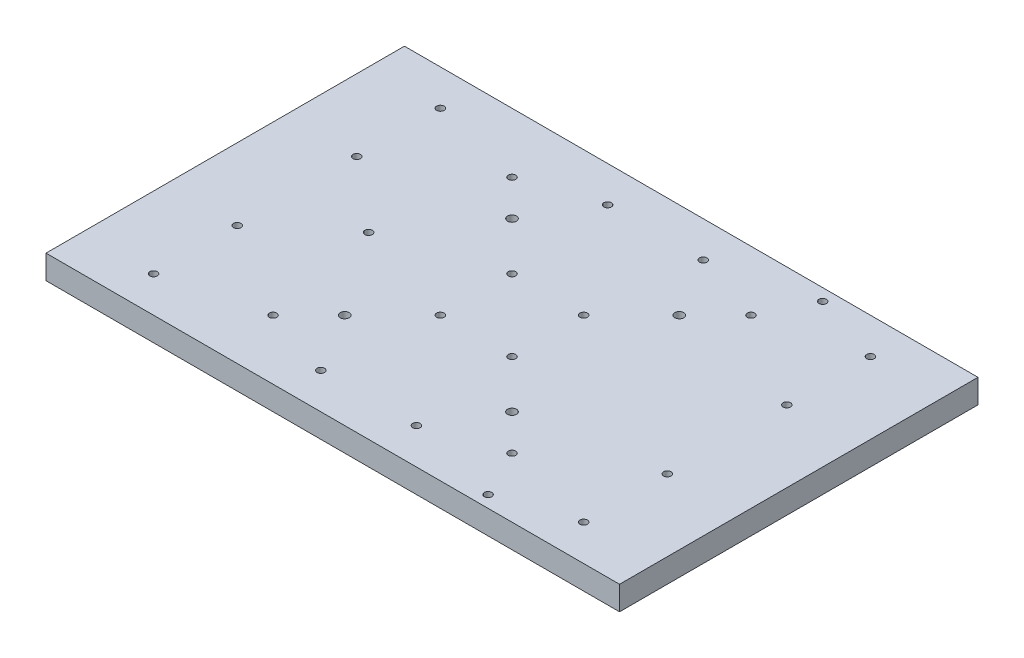
from build123d import *

# Parameters (mm, degrees)
SKETCH2_W                   = 609.6
SKETCH2_H                   = 381
BOSS_EXTRUDE1_DEPTH         = 12.7
SKETCH3_R                   = 4.7625
CUT_EXTRUDE1_DEPTH          = 26.4
F_3_8_16_TAPPED_HOLE1_D     = 7.9375
F_3_8_16_TAPPED_HOLE1_DEPTH = 25.401
F_3_8_16_TAPPED_HOLE2_D     = 7.9375
F_3_8_16_TAPPED_HOLE2_DEPTH = 25.4
MIRROR2_COPY_1_SKETCH_R     = 4.7625
MIRROR2_COPY_1_DEPTH        = 26.4
MIRROR2_COPY_2_D            = 7.9375
MIRROR2_COPY_2_DEPTH        = 25.401


with BuildPart() as part:
    # Sketch2 → Boss-Extrude1 (new body, symmetric)
    with BuildSketch(Plane(origin=(0, 0, 0), x_dir=(1, 0, 0), z_dir=(0, 1, 0))):
        Rectangle(SKETCH2_W, SKETCH2_H)
    extrude(amount=BOSS_EXTRUDE1_DEPTH, both=True)

    # Sketch3 → Cut-Extrude1 (cut, through all)
    with BuildSketch(Plane(origin=(0, 12.7, 0), x_dir=(1, 0, 0), z_dir=(0, 1, 0))):
        with Locations((88.9, 88.9)):
            Circle(SKETCH3_R)
    cut_extrude1 = extrude(amount=-CUT_EXTRUDE1_DEPTH, mode=Mode.SUBTRACT)

    # 3/8-16 Tapped Hole1
    with Locations(Plane(origin=(0, 12.7, 0), x_dir=(1, 0, 0), z_dir=(0, 1, 0))):
        with Locations((127, 127), (38.1, 38.1), (228.6, 63.5), (228.6, 152.4), (50.8, 152.4)):
            f_3_8_16_tapped_hole1 = Hole(F_3_8_16_TAPPED_HOLE1_D / 2, depth=F_3_8_16_TAPPED_HOLE1_DEPTH)

    # 3/8-16 Tapped Hole2
    with Locations(Plane(origin=(0, 12.7, 0), x_dir=(1, 0, 0), z_dir=(0, 1, 0))):
        with Locations((152.4, 177.8), (152.4, -177.8), (-152.4, 0)):
            Hole(F_3_8_16_TAPPED_HOLE2_D / 2, depth=F_3_8_16_TAPPED_HOLE2_DEPTH)

    # Mirror1: Cut-Extrude1, 3/8-16 Tapped Hole1 across plane
    add(cut_extrude1.mirror(Plane.XY), mode=Mode.SUBTRACT)
    add(f_3_8_16_tapped_hole1.mirror(Plane.XY), mode=Mode.SUBTRACT)

    # Mirror2: 3/8-16 Tapped Hole1, Cut-Extrude1 across plane
    add(f_3_8_16_tapped_hole1.mirror(Plane(origin=(0, 0, 0), x_dir=(0, 0, 1), z_dir=(1, 0, 0))), mode=Mode.SUBTRACT)
    add(cut_extrude1.mirror(Plane(origin=(0, 0, 0), x_dir=(0, 0, 1), z_dir=(1, 0, 0))), mode=Mode.SUBTRACT)

    # Mirror2 copy 1 sketch → Mirror2 copy 1 (cut, through all)
    with BuildSketch(Plane(origin=(0, 12.7, 0), x_dir=(-1, 0, 0), z_dir=(0, 1, 0))):
        with Locations((88.9, 88.9)):
            Circle(MIRROR2_COPY_1_SKETCH_R)
    extrude(amount=-MIRROR2_COPY_1_DEPTH, mode=Mode.SUBTRACT)

    # Mirror2 copy 2
    with Locations(Plane(origin=(0, 12.7, 0), x_dir=(-1, 0, 0), z_dir=(0, 1, 0))):
        with Locations((127, 127), (38.1, 38.1), (228.6, 63.5), (228.6, 152.4), (50.8, 152.4)):
            Hole(MIRROR2_COPY_2_D / 2, depth=MIRROR2_COPY_2_DEPTH)


solid = part.part
